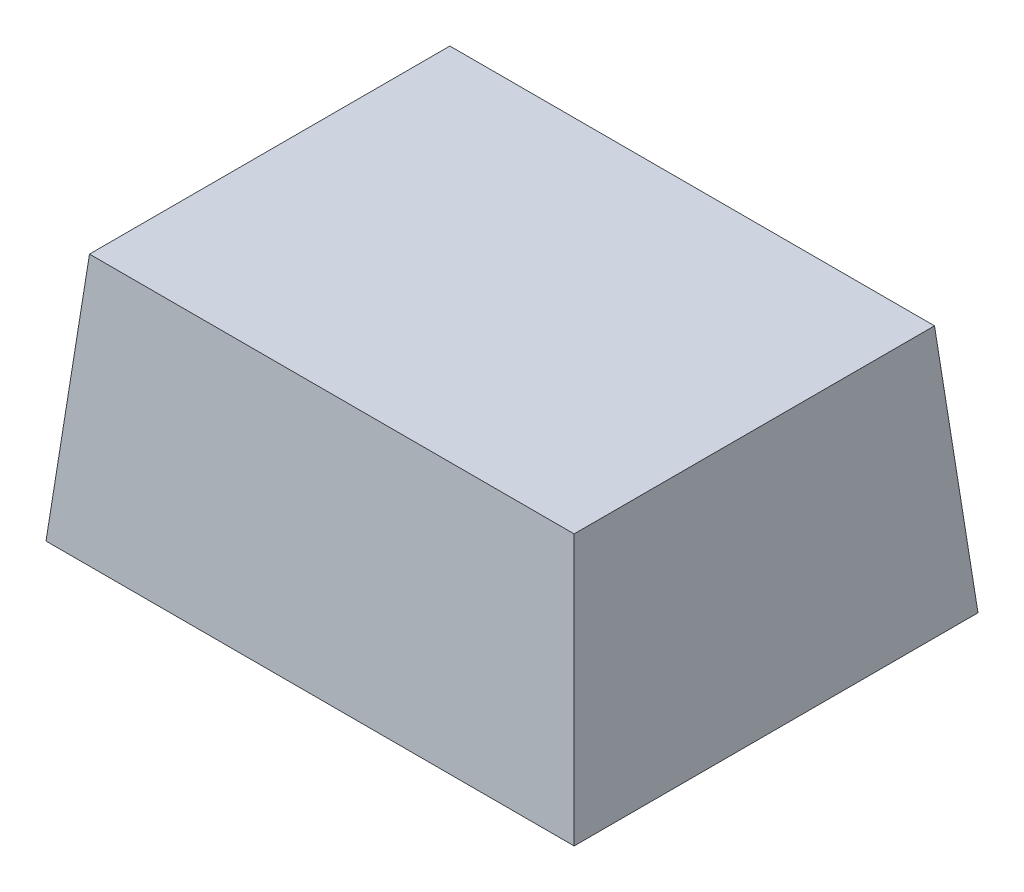
from build123d import *

# Parameters (mm, degrees)
SKETCH1_W           = 0.85
SKETCH1_H           = 0.65
BOSS_EXTRUDE1_DEPTH = 0.4
BOSS_EXTRUDE1_TAPER = 5


with BuildPart() as part:
    # Sketch1 → Boss-Extrude1 (new body)
    with BuildSketch(Plane(origin=(0, 0, 0), x_dir=(1, 0, 0), z_dir=(0, 1, 0))):
        Rectangle(SKETCH1_W, SKETCH1_H)
    extrude(amount=BOSS_EXTRUDE1_DEPTH, taper=BOSS_EXTRUDE1_TAPER)


solid = part.part
